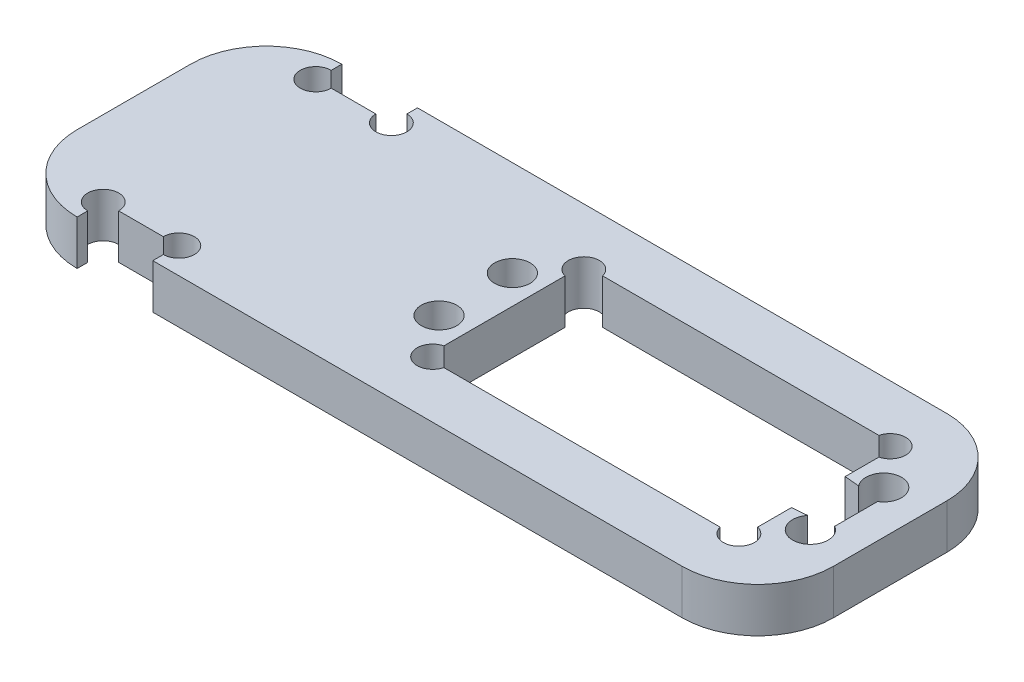
from build123d import *

# Parameters (mm, degrees)
SKETCH1_W           = 100
SKETCH1_H           = 35
SKETCH1_R           = 2.35
SKETCH1_W_2         = 40.5
SKETCH1_H_2         = 20
BOSS_EXTRUDE1_DEPTH = 5.9
FILLET1_R           = 10
SKETCH3_W           = 10
SKETCH3_H           = 3.45
CUT_EXTRUDE2_DEPTH  = 10
CUT_EXTRUDE3_REACH  = 7.9
SKETCH4_R           = 2.05
CUT_EXTRUDE4_REACH  = 7.9
CUT_EXTRUDE5_START  = -5.9
SKETCH7_W           = 41.5
SKETCH7_H           = 21
CUT_EXTRUDE5_DEPTH  = 5.9


with BuildPart() as part:
    # Sketch1 → Boss-Extrude1 (new body)
    with BuildSketch(Plane(origin=(0, 0, 0), x_dir=(1, 0, 0), z_dir=(0, 1, 0))):
        Rectangle(SKETCH1_W, SKETCH1_H)
        with Locations((-4.8, 4.85)):
            Circle(SKETCH1_R, mode=Mode.SUBTRACT)
        with Locations((-4.8, -4.85)):
            Circle(SKETCH1_R, mode=Mode.SUBTRACT)
        with Locations((44.3, -4.85)):
            Circle(SKETCH1_R, mode=Mode.SUBTRACT)
        with Locations((44.3, 4.85)):
            Circle(SKETCH1_R, mode=Mode.SUBTRACT)
        with Locations((19.75, 0)):
            Rectangle(SKETCH1_W_2, SKETCH1_H_2, mode=Mode.SUBTRACT)
    extrude(amount=BOSS_EXTRUDE1_DEPTH)

    # Fillet1
    fillet1_edges = [part.edges().sort_by_distance(p)[0] for p in [
        (50, 2.95, 17.5),
        (-50, 2.95, 17.5),
        (-50, 2.95, -17.5),
        (50, 2.95, -17.5),
    ]]
    fillet(fillet1_edges, radius=FILLET1_R)

    # Sketch3 → Cut-Extrude2 (cut)
    with BuildSketch(Plane(origin=(0, 5.9, 0), x_dir=(1, 0, 0), z_dir=(0, 1, 0))):
        with Locations((-35, 15.775)):
            Rectangle(SKETCH3_W, SKETCH3_H)
        with Locations((-35, -15.775)):
            Rectangle(SKETCH3_W, SKETCH3_H)
    extrude(amount=-CUT_EXTRUDE2_DEPTH, mode=Mode.SUBTRACT)

    # Sketch4 → Cut-Extrude3 (cut, up to next)
    with BuildSketch(Plane(origin=(0, 5.9, 0), x_dir=(1, 0, 0), z_dir=(0, 1, 0)), mode=Mode.PRIVATE) as cut_extrude3_sk1:
        with Locations((-30, 14.05)):
            Circle(SKETCH4_R)
    cut_extrude3_tool1 = extrude(cut_extrude3_sk1.sketch, amount=-CUT_EXTRUDE3_REACH, mode=Mode.PRIVATE) & part.part
    add(cut_extrude3_tool1.solids().sort_by_distance((-30, 5.9, -14.05))[0], mode=Mode.SUBTRACT)
    # Sketch4 → Cut-Extrude3 (cut, up to next)
    with BuildSketch(Plane(origin=(0, 5.9, 0), x_dir=(1, 0, 0), z_dir=(0, 1, 0)), mode=Mode.PRIVATE) as cut_extrude3_sk2:
        with Locations((-40, 14.05)):
            Circle(SKETCH4_R)
    cut_extrude3_tool2 = extrude(cut_extrude3_sk2.sketch, amount=-CUT_EXTRUDE3_REACH, mode=Mode.PRIVATE) & part.part
    add(cut_extrude3_tool2.solids().sort_by_distance((-40, 5.9, -14.05))[0], mode=Mode.SUBTRACT)
    # Sketch4 → Cut-Extrude3 (cut, up to next)
    with BuildSketch(Plane(origin=(0, 5.9, 0), x_dir=(1, 0, 0), z_dir=(0, 1, 0)), mode=Mode.PRIVATE) as cut_extrude3_sk3:
        with Locations((-40, -14.05)):
            Circle(SKETCH4_R)
    cut_extrude3_tool3 = extrude(cut_extrude3_sk3.sketch, amount=-CUT_EXTRUDE3_REACH, mode=Mode.PRIVATE) & part.part
    add(cut_extrude3_tool3.solids().sort_by_distance((-40, 5.9, 14.05))[0], mode=Mode.SUBTRACT)
    # Sketch4 → Cut-Extrude3 (cut, up to next)
    with BuildSketch(Plane(origin=(0, 5.9, 0), x_dir=(1, 0, 0), z_dir=(0, 1, 0)), mode=Mode.PRIVATE) as cut_extrude3_sk4:
        with Locations((-30, -14.05)):
            Circle(SKETCH4_R)
    cut_extrude3_tool4 = extrude(cut_extrude3_sk4.sketch, amount=-CUT_EXTRUDE3_REACH, mode=Mode.PRIVATE) & part.part
    add(cut_extrude3_tool4.solids().sort_by_distance((-30, 5.9, 14.05))[0], mode=Mode.SUBTRACT)
    # Sketch4 → Cut-Extrude3 (cut, up to next)
    with BuildSketch(Plane(origin=(0, 5.9, 0), x_dir=(1, 0, 0), z_dir=(0, 1, 0)), mode=Mode.PRIVATE) as cut_extrude3_sk5:
        with Locations((-0.5, 10)):
            Circle(SKETCH4_R)
    cut_extrude3_tool5 = extrude(cut_extrude3_sk5.sketch, amount=-CUT_EXTRUDE3_REACH, mode=Mode.PRIVATE) & part.part
    add(cut_extrude3_tool5.solids().sort_by_distance((-0.5, 5.9, -10))[0], mode=Mode.SUBTRACT)
    # Sketch4 → Cut-Extrude3 (cut, up to next)
    with BuildSketch(Plane(origin=(0, 5.9, 0), x_dir=(1, 0, 0), z_dir=(0, 1, 0)), mode=Mode.PRIVATE) as cut_extrude3_sk6:
        with Locations((-0.5, -10)):
            Circle(SKETCH4_R)
    cut_extrude3_tool6 = extrude(cut_extrude3_sk6.sketch, amount=-CUT_EXTRUDE3_REACH, mode=Mode.PRIVATE) & part.part
    add(cut_extrude3_tool6.solids().sort_by_distance((-0.5, 5.9, 10))[0], mode=Mode.SUBTRACT)
    # Sketch4 → Cut-Extrude3 (cut, up to next)
    with BuildSketch(Plane(origin=(0, 5.9, 0), x_dir=(1, 0, 0), z_dir=(0, 1, 0)), mode=Mode.PRIVATE) as cut_extrude3_sk7:
        with Locations((40, -10)):
            Circle(SKETCH4_R)
    cut_extrude3_tool7 = extrude(cut_extrude3_sk7.sketch, amount=-CUT_EXTRUDE3_REACH, mode=Mode.PRIVATE) & part.part
    add(cut_extrude3_tool7.solids().sort_by_distance((40, 5.9, 10))[0], mode=Mode.SUBTRACT)
    # Sketch4 → Cut-Extrude3 (cut, up to next)
    with BuildSketch(Plane(origin=(0, 5.9, 0), x_dir=(1, 0, 0), z_dir=(0, 1, 0)), mode=Mode.PRIVATE) as cut_extrude3_sk8:
        with Locations((40, 10)):
            Circle(SKETCH4_R)
    cut_extrude3_tool8 = extrude(cut_extrude3_sk8.sketch, amount=-CUT_EXTRUDE3_REACH, mode=Mode.PRIVATE) & part.part
    add(cut_extrude3_tool8.solids().sort_by_distance((40, 5.9, -10))[0], mode=Mode.SUBTRACT)

    # Sketch6 → Cut-Extrude4 (cut, up to next)
    with BuildSketch(Plane(origin=(0, 5.9, 0), x_dir=(1, 0, 0), z_dir=(0, 1, 0)), mode=Mode.PRIVATE) as cut_extrude4_sk1:
        Polygon((40, -3.1), (40, 3.1), (40, 3.6), (45.5, 3.1), (45.5, -3.1), (40, -3.6), align=None)
    cut_extrude4_tool1 = extrude(cut_extrude4_sk1.sketch, amount=-CUT_EXTRUDE4_REACH, mode=Mode.PRIVATE) & part.part
    add(cut_extrude4_tool1.solids().sort_by_distance((42.681592, 5.9, 0))[0], mode=Mode.SUBTRACT)

    # Sketch7 → Cut-Extrude5 (cut)
    with BuildSketch(Plane(origin=(0, 5.9, 0), x_dir=(1, 0, 0), z_dir=(0, 1, 0)).offset(CUT_EXTRUDE5_START)):
        with Locations((19.75, 0)):
            Rectangle(SKETCH7_W, SKETCH7_H)
    extrude(amount=CUT_EXTRUDE5_DEPTH, mode=Mode.SUBTRACT)


solid = part.part
